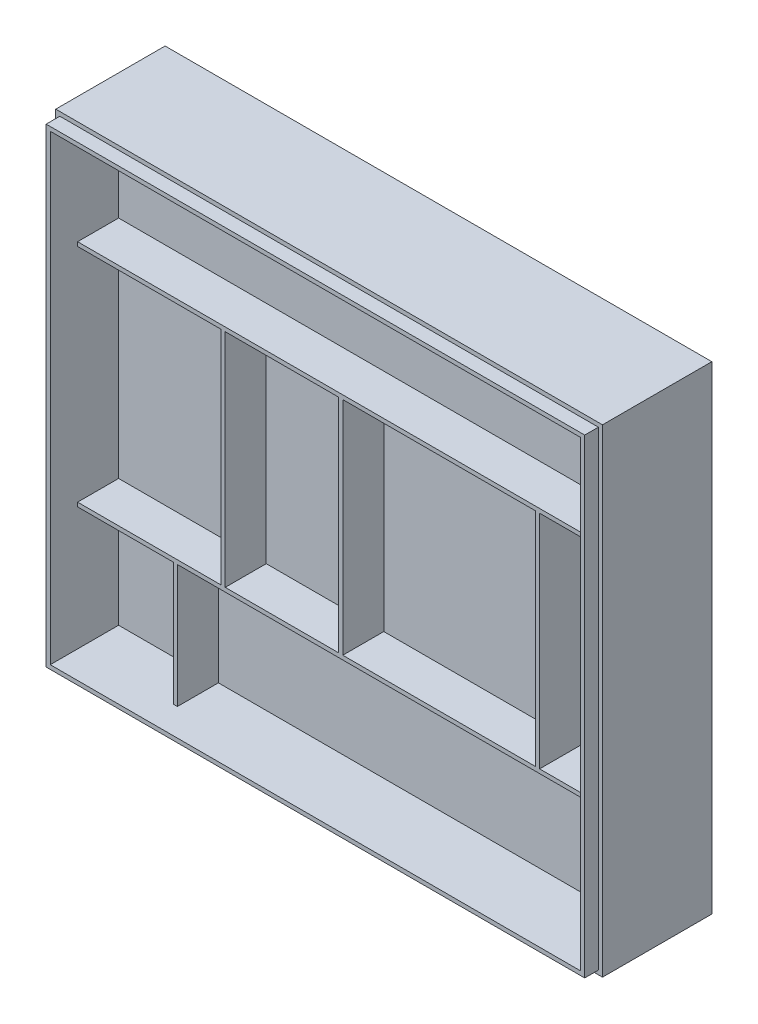
from build123d import *

# Parameters (mm, degrees)
SKETCH_1_W          = 400
SKETCH_1_H          = 350
EXTRUDE_1_DEPTH     = 80
SKETCH_2_W          = 394
SKETCH_2_H          = 344
EXTRUDE_2_DEPTH     = 10
SKETCH_3_W          = 388
SKETCH_3_H          = 338
CUT_EXTRUDE_1_DEPTH = 50
SKETCH_4_W          = 388
SKETCH_4_H          = 3
EXTRUDE_3_DEPTH     = 30
SKETCH_5_W          = 3
SKETCH_5_H          = 162
SKETCH_5_H_2        = 90
EXTRUDE_4_DEPTH     = 30
SKETCH_6_W          = 350
SKETCH_6_H          = 34
CUT_EXTRUDE_2_DEPTH = 320
CHAMFER_1_SIZE      = 20


with BuildPart() as part:
    # 草图1 → 凸台-拉伸1 (new body)
    with BuildSketch(Plane.XY):
        Rectangle(SKETCH_1_W, SKETCH_1_H)
    extrude(amount=EXTRUDE_1_DEPTH)

    # 草图2 → 凸台-拉伸2 (add)
    with BuildSketch(Plane.XY.offset(80)):
        Rectangle(SKETCH_2_W, SKETCH_2_H)
    extrude(amount=EXTRUDE_2_DEPTH)

    # 草图3 → 切除-拉伸1 (cut)
    with BuildSketch(Plane.XY.offset(90)):
        Rectangle(SKETCH_3_W, SKETCH_3_H)
    extrude(amount=-CUT_EXTRUDE_1_DEPTH, mode=Mode.SUBTRACT)

    # 草图4 → 凸台-拉伸3 (add)
    with BuildSketch(Plane.XY.offset(40)):
        with Locations((0, 87.5)):
            Rectangle(SKETCH_4_W, SKETCH_4_H)
        with Locations((0, -77.5)):
            Rectangle(SKETCH_4_W, SKETCH_4_H)
    extrude(amount=EXTRUDE_3_DEPTH)

    # 草图5 → 凸台-拉伸4 (add)
    with BuildSketch(Plane.XY.offset(40)):
        with Locations((-87.5, 5)):
            Rectangle(SKETCH_5_W, SKETCH_5_H)
        with Locations((-1.5, 5)):
            Rectangle(SKETCH_5_W, SKETCH_5_H)
        with Locations((142.5, 5)):
            Rectangle(SKETCH_5_W, SKETCH_5_H)
        with Locations((-122.5, -124)):
            Rectangle(SKETCH_5_W, SKETCH_5_H_2)
    extrude(amount=EXTRUDE_4_DEPTH)

    # 草图6 → 切除-拉伸2 (cut)
    with BuildSketch(Plane.XZ.offset(175)):
        with Locations((0, 20)):
            Rectangle(SKETCH_6_W, SKETCH_6_H)
    extrude(amount=-CUT_EXTRUDE_2_DEPTH, mode=Mode.SUBTRACT)

    # 倒角1
    chamfer_1_edges = [part.edges().sort_by_distance(p)[0] for p in [
        (175, -175, 20),
        (-175, -175, 20),
    ]]
    chamfer(chamfer_1_edges, length=CHAMFER_1_SIZE)


solid = part.part
